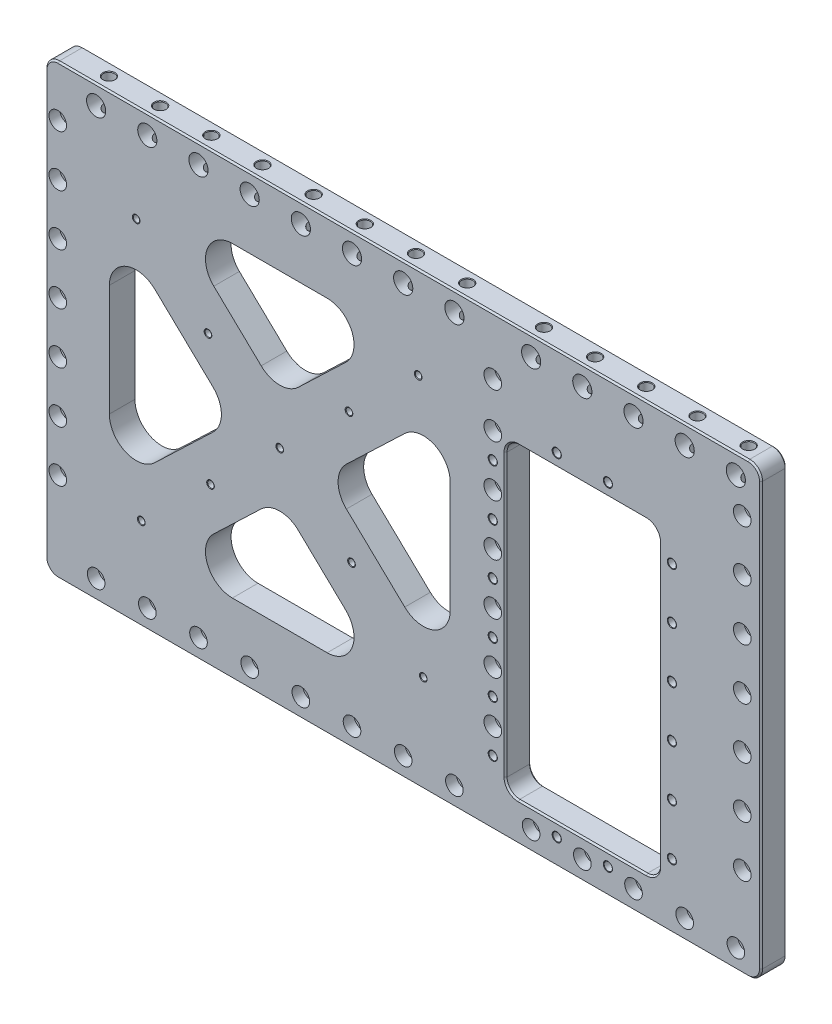
from build123d import *

# Parameters (mm, degrees)
SKETCH1_W                                     = 710.438
SKETCH1_H                                     = 444.5
EXTRUDE1_DEPTH                                = 12.7
CBORE_FOR_3_8_SOCKET_HEAD_CAP_SCREW1_AT_COUNT = 2
CBORE_FOR_3_8_SOCKET_HEAD_CAP_SCREW1_AT_PITCH = 679.45
LPATTERN1_COUNT                               = 4
LPATTERN1_PITCH                               = 50.8
LPATTERN1_COL_COUNT                           = 4
LPATTERN1_COL_PITCH                           = 50.8
CUT_EXTRUDE2_DEPTH                            = 26.4
FILLET2_R                                     = 26.67
F_3_4_0_75_DIAMETER_HOLE1_D                   = 19.05
LPATTERN4_COUNT                               = 4
LPATTERN4_PITCH                               = 50.8
LPATTERN4_COL_COUNT                           = 5
LPATTERN4_COL_PITCH                           = 50.8
LPATTERN5_COUNT                               = 3
LPATTERN5_PITCH                               = 50.8
LPATTERN5_COL_COUNT                           = 4
LPATTERN5_COL_PITCH                           = 50.8
F_1_4_20_TAPPED_HOLE1_AT_2_COUNT              = 2
F_1_4_20_TAPPED_HOLE1_AT_2_PITCH              = 190.037921495
F_1_4_20_TAPPED_HOLE1_AT_3_COUNT              = 2
F_1_4_20_TAPPED_HOLE1_AT_3_PITCH              = 95.018960748
F_1_4_20_TAPPED_HOLE1_AT_4_COUNT              = 2
F_1_4_20_TAPPED_HOLE1_AT_4_PITCH              = 205.096633952
F_1_4_20_TAPPED_HOLE1_AT_5_COUNT              = 2
F_1_4_20_TAPPED_HOLE1_AT_5_PITCH              = 257.044845725
F_1_4_20_TAPPED_HOLE1_AT_6_COUNT              = 2
F_1_4_20_TAPPED_HOLE1_AT_6_PITCH              = 380.07584299
F_1_4_20_TAPPED_HOLE1_AT_7_COUNT              = 2
F_1_4_20_TAPPED_HOLE1_AT_7_PITCH              = 285.056882243
F_1_4_20_TAPPED_HOLE1_AT_8_COUNT              = 2
F_1_4_20_TAPPED_HOLE1_AT_8_PITCH              = 219.593715204
F_1_4_20_TAPPED_HOLE1_AT_9_COUNT              = 2
F_1_4_20_TAPPED_HOLE1_AT_9_PITCH              = 279.974273302
F_3_4_0_75_DIAMETER_HOLE2_D                   = 19.05
LPATTERN6_COUNT                               = 5
LPATTERN6_PITCH                               = 50.8
FILLET3_R                                     = 12.7
CHAMFER1_SIZE                                 = 1.524
CUT_EXTRUDE5_DEPTH                            = 26.4000001
TAPPED_HOLE_FOR_1_4_20_HELICOIL1_AT_2_COUNT   = 2
TAPPED_HOLE_FOR_1_4_20_HELICOIL1_AT_2_PITCH   = 50.8
TAPPED_HOLE_FOR_1_4_20_HELICOIL1_AT_3_COUNT   = 2
TAPPED_HOLE_FOR_1_4_20_HELICOIL1_AT_3_PITCH   = 101.6
TAPPED_HOLE_FOR_1_4_20_HELICOIL1_AT_4_COUNT   = 2
TAPPED_HOLE_FOR_1_4_20_HELICOIL1_AT_4_PITCH   = 152.4
TAPPED_HOLE_FOR_1_4_20_HELICOIL1_AT_5_COUNT   = 2
TAPPED_HOLE_FOR_1_4_20_HELICOIL1_AT_5_PITCH   = 200.804631421
TAPPED_HOLE_FOR_1_4_20_HELICOIL1_AT_6_COUNT   = 2
TAPPED_HOLE_FOR_1_4_20_HELICOIL1_AT_6_PITCH   = 222.159267194
TAPPED_HOLE_FOR_1_4_20_HELICOIL1_AT_7_COUNT   = 2
TAPPED_HOLE_FOR_1_4_20_HELICOIL1_AT_7_PITCH   = 234.176429215
TAPPED_HOLE_FOR_1_4_20_HELICOIL1_AT_8_COUNT   = 2
TAPPED_HOLE_FOR_1_4_20_HELICOIL1_AT_8_PITCH   = 204.781346807
TAPPED_HOLE_FOR_1_4_20_HELICOIL1_AT_9_COUNT   = 2
TAPPED_HOLE_FOR_1_4_20_HELICOIL1_AT_9_PITCH   = 184.914791188
TAPPED_HOLE_FOR_1_4_20_HELICOIL1_AT_10_COUNT  = 2
TAPPED_HOLE_FOR_1_4_20_HELICOIL1_AT_10_PITCH  = 177.8
TAPPED_HOLE_FOR_1_4_20_HELICOIL1_AT_11_COUNT  = 2
TAPPED_HOLE_FOR_1_4_20_HELICOIL1_AT_11_PITCH  = 184.914791188
TAPPED_HOLE_FOR_1_4_20_HELICOIL1_AT_12_COUNT  = 2
TAPPED_HOLE_FOR_1_4_20_HELICOIL1_AT_12_PITCH  = 204.781346807
TAPPED_HOLE_FOR_1_4_20_HELICOIL1_AT_13_COUNT  = 2
TAPPED_HOLE_FOR_1_4_20_HELICOIL1_AT_13_PITCH  = 153.454683865
TAPPED_HOLE_FOR_1_4_20_HELICOIL1_AT_14_COUNT  = 2
TAPPED_HOLE_FOR_1_4_20_HELICOIL1_AT_14_PITCH  = 180.500914125
TAPPED_HOLE_FOR_1_4_20_HELICOIL1_AT_15_COUNT  = 2
TAPPED_HOLE_FOR_1_4_20_HELICOIL1_AT_15_PITCH  = 50.8
TAPPED_HOLE_FOR_1_4_20_HELICOIL1_AT_16_COUNT  = 2
TAPPED_HOLE_FOR_1_4_20_HELICOIL1_AT_16_PITCH  = 101.6
CHAMFER2_SIZE                                 = 1.524
EXTRUDE2_DEPTH                                = 12.7
LPATTERN7_COUNT                               = 6
LPATTERN7_PITCH                               = 50.8
EXTRUDE3_DEPTH                                = 12.7
LPATTERN8_COUNT                               = 2
LPATTERN8_PITCH                               = 50.8


with BuildPart() as part:
    # Sketch1 → Extrude1 (new body, symmetric)
    with BuildSketch(Plane.XY):
        Rectangle(SKETCH1_W, SKETCH1_H)
    extrude(amount=EXTRUDE1_DEPTH, both=True)

    # Sketch2 → CBORE for 3/8 Socket Head Cap Screw1 (revolve, cut)
    with BuildSketch(Plane(origin=(-342.9, 19.05, 12.7), x_dir=(0, -1, 0), z_dir=(1, 0, 0))):
        Polygon((0, 0), (0, 25.4), (5.842, 25.4), (5.15874, 24.613999282), (5.15874, 10.668), (8.7376, 10.668), (8.7376, 0), align=None)
    cbore_for_3_8_socket_head_cap_screw1 = revolve(axis=Axis((-342.9, 19.05, 19.05), (0, 0, -1)), mode=Mode.SUBTRACT)

    # CBORE for 3/8 Socket Head Cap Screw1 at: CBORE for 3/8 Socket Head Cap Screw1 ×2
    with Locations(*[(i * CBORE_FOR_3_8_SOCKET_HEAD_CAP_SCREW1_AT_PITCH, 0, 0) for i in range(1, CBORE_FOR_3_8_SOCKET_HEAD_CAP_SCREW1_AT_COUNT)]):
        add(cbore_for_3_8_socket_head_cap_screw1, mode=Mode.SUBTRACT)

    # LPattern1: CBORE for 3/8 Socket Head Cap Screw1 ×4
    with Locations(*[(0, -i * LPATTERN1_PITCH, 0) for i in range(1, LPATTERN1_COUNT)]):
        add(cbore_for_3_8_socket_head_cap_screw1, mode=Mode.SUBTRACT)

    # LPattern1 copy 1 sketch → LPattern1 copy 1 (revolve, cut)
    with BuildSketch(Plane(origin=(336.55, -31.75, 12.7), x_dir=(0, -1, 0), z_dir=(1, 0, 0))):
        Polygon((0, 0), (0, 25.4), (5.842, 25.4), (5.15874, 24.613999282), (5.15874, 10.668), (8.7376, 10.668), (8.7376, 0), align=None)
    revolve(axis=Axis((336.55, -31.75, 19.05), (0, 0, -1)), mode=Mode.SUBTRACT)

    # LPattern1 copy 2 sketch → LPattern1 copy 2 (revolve, cut)
    with BuildSketch(Plane(origin=(336.55, -82.55, 12.7), x_dir=(0, -1, 0), z_dir=(1, 0, 0))):
        Polygon((0, 0), (0, 25.4), (5.842, 25.4), (5.15874, 24.613999282), (5.15874, 10.668), (8.7376, 10.668), (8.7376, 0), align=None)
    revolve(axis=Axis((336.55, -82.55, 19.05), (0, 0, -1)), mode=Mode.SUBTRACT)

    # LPattern1 copy 3 sketch → LPattern1 copy 3 (revolve, cut)
    with BuildSketch(Plane(origin=(336.55, -133.35, 12.7), x_dir=(0, -1, 0), z_dir=(1, 0, 0))):
        Polygon((0, 0), (0, 25.4), (5.842, 25.4), (5.15874, 24.613999282), (5.15874, 10.668), (8.7376, 10.668), (8.7376, 0), align=None)
    revolve(axis=Axis((336.55, -133.35, 19.05), (0, 0, -1)), mode=Mode.SUBTRACT)

    # LPattern1 col: CBORE for 3/8 Socket Head Cap Screw1 ×4
    with Locations(*[(0, i * LPATTERN1_COL_PITCH, 0) for i in range(1, LPATTERN1_COL_COUNT)]):
        add(cbore_for_3_8_socket_head_cap_screw1, mode=Mode.SUBTRACT)

    # LPattern1 col copy 1 sketch → LPattern1 col copy 1 (revolve, cut)
    with BuildSketch(Plane(origin=(336.55, 69.85, 12.7), x_dir=(0, -1, 0), z_dir=(1, 0, 0))):
        Polygon((0, 0), (0, 25.4), (5.842, 25.4), (5.15874, 24.613999282), (5.15874, 10.668), (8.7376, 10.668), (8.7376, 0), align=None)
    revolve(axis=Axis((336.55, 69.85, 19.05), (0, 0, -1)), mode=Mode.SUBTRACT)

    # LPattern1 col copy 2 sketch → LPattern1 col copy 2 (revolve, cut)
    with BuildSketch(Plane(origin=(336.55, 120.65, 12.7), x_dir=(0, -1, 0), z_dir=(1, 0, 0))):
        Polygon((0, 0), (0, 25.4), (5.842, 25.4), (5.15874, 24.613999282), (5.15874, 10.668), (8.7376, 10.668), (8.7376, 0), align=None)
    revolve(axis=Axis((336.55, 120.65, 19.05), (0, 0, -1)), mode=Mode.SUBTRACT)

    # LPattern1 col copy 3 sketch → LPattern1 col copy 3 (revolve, cut)
    with BuildSketch(Plane(origin=(336.55, 171.45, 12.7), x_dir=(0, -1, 0), z_dir=(1, 0, 0))):
        Polygon((0, 0), (0, 25.4), (5.842, 25.4), (5.15874, 24.613999282), (5.15874, 10.668), (8.7376, 10.668), (8.7376, 0), align=None)
    revolve(axis=Axis((336.55, 171.45, 19.05), (0, 0, -1)), mode=Mode.SUBTRACT)

    # Sketch9 → Cut-Extrude2 (cut, through all)
    with BuildSketch(Plane.XY.offset(12.7)):
        Polygon((-8.969055228, 152.4), (-122.5485484, 43.907313525), (-236.128041572, 152.4), align=None)
        Polygon((-291.719, 117.686617331), (-168.514507754, 0), (-291.719, -117.686617331), align=None)
        Polygon((-122.5485484, -43.907313525), (-236.128041572, -152.4), (-8.969055228, -152.4), align=None)
        Polygon((46.6219032, 117.686617331), (46.6219032, -117.686617331), (-76.582589046, 0), align=None)
    extrude(amount=-CUT_EXTRUDE2_DEPTH, mode=Mode.SUBTRACT)

    # Fillet2
    fillet2_edges = [part.edges().sort_by_distance(p)[0] for p in [
        (-236.128041572, 152.4, 0),
        (-8.969055228, 152.4, 0),
        (-122.5485484, 43.907313525, 0),
        (-291.719, -117.686617331, 0),
        (-291.719, 117.686617331, 0),
        (-168.514507754, 0, 0),
        (-122.5485484, -43.907313525, 0),
        (-8.969055228, -152.4, 0),
        (-236.128041572, -152.4, 0),
        (-76.582589046, 0, 0),
        (46.6219032, 117.686617331, 0),
        (46.6219032, -117.686617331, 0),
    ]]
    fillet(fillet2_edges, radius=FILLET2_R)

    # Sketch4 → CBORE for 3/8 Socket Head Cap Screw2 (revolve, cut)
    with BuildSketch(Plane(origin=(-152.4, -203.2, 12.7), x_dir=(0, -1, 0), z_dir=(1, 0, 0))):
        Polygon((0, 0), (0, 25.4), (5.842, 25.4), (5.15874, 24.613999282), (5.15874, 10.668), (8.7376, 10.668), (8.7376, 0), align=None)
    cbore_for_3_8_socket_head_cap_screw2 = revolve(axis=Axis((-152.4, -203.2, 19.05), (0, 0, -1)), mode=Mode.SUBTRACT)

    # Sketch14 → 7/16 (0.4375) Diameter Hole1 (revolve, cut)
    with BuildSketch(Plane(origin=(-152.4, 222.25, 0), x_dir=(0, 0, 1), z_dir=(1, 0, 0))):
        Polygon((0, 0), (0, 38.263531814), (5.55625, 34.925), (5.55625, 0.620911348), (6.096, 0), align=None)
    f_7_16_0_4375_diameter_hole1 = revolve(axis=Axis((-152.4, 228.6, 0), (0, -1, 0)), mode=Mode.SUBTRACT)

    # 3/4 (0.75) Diameter Hole1 (through all)
    with Locations(Plane.XY.offset(12.7)):
        with Locations((-152.4, 203.2)):
            f_3_4_0_75_diameter_hole1 = Hole(F_3_4_0_75_DIAMETER_HOLE1_D / 2)

    # LPattern4: CBORE for 3/8 Socket Head Cap Screw2, 7/16 (0.4375) Diameter Hole1, 3/4 (0.75) Diameter Hole1 ×4
    with Locations(*[(-i * LPATTERN4_PITCH, 0, 0) for i in range(1, LPATTERN4_COUNT)]):
        add(cbore_for_3_8_socket_head_cap_screw2, mode=Mode.SUBTRACT)
        add(f_7_16_0_4375_diameter_hole1, mode=Mode.SUBTRACT)
        add(f_3_4_0_75_diameter_hole1, mode=Mode.SUBTRACT)

    # LPattern4 col: CBORE for 3/8 Socket Head Cap Screw2, 7/16 (0.4375) Diameter Hole1, 3/4 (0.75) Diameter Hole1 ×5
    with Locations(*[(i * LPATTERN4_COL_PITCH, 0, 0) for i in range(1, LPATTERN4_COL_COUNT)]):
        add(cbore_for_3_8_socket_head_cap_screw2, mode=Mode.SUBTRACT)
        add(f_7_16_0_4375_diameter_hole1, mode=Mode.SUBTRACT)
        add(f_3_4_0_75_diameter_hole1, mode=Mode.SUBTRACT)

    # Sketch16 → CBORE for 3/8 Socket Head Cap Screw3 (revolve, cut)
    with BuildSketch(Plane(origin=(88.9, 19.05, 12.7), x_dir=(0, -1, 0), z_dir=(1, 0, 0))):
        Polygon((0, 0), (0, 25.4), (5.842, 25.4), (5.15874, 24.613999282), (5.15874, 10.668), (8.7376, 10.668), (8.7376, 0), align=None)
    cbore_for_3_8_socket_head_cap_screw3 = revolve(axis=Axis((88.9, 19.05, 19.05), (0, 0, -1)), mode=Mode.SUBTRACT)

    # LPattern5: CBORE for 3/8 Socket Head Cap Screw3 ×3
    with Locations(*[(0, i * LPATTERN5_PITCH, 0) for i in range(1, LPATTERN5_COUNT)]):
        add(cbore_for_3_8_socket_head_cap_screw3, mode=Mode.SUBTRACT)

    # LPattern5 col: CBORE for 3/8 Socket Head Cap Screw3 ×4
    with Locations(*[(0, -i * LPATTERN5_COL_PITCH, 0) for i in range(1, LPATTERN5_COL_COUNT)]):
        add(cbore_for_3_8_socket_head_cap_screw3, mode=Mode.SUBTRACT)

    # Sketch27 → CBORE for 3/8 Socket Head Cap Screw4 (revolve, cut)
    with BuildSketch(Plane(origin=(88.9, 165.1, 12.7), x_dir=(0, -1, 0), z_dir=(1, 0, 0))):
        Polygon((0, 0), (0, 25.4), (5.842, 25.4), (5.15874, 24.613999282), (5.15874, 10.668), (8.7376, 10.668), (8.7376, 0), align=None)
    revolve(axis=Axis((88.9, 165.1, 19.05), (0, 0, -1)), mode=Mode.SUBTRACT)

    # Sketch24 → 1/4-20 Tapped Hole1 (revolve, cut)
    with BuildSketch(Plane(origin=(19.9519032, -125.73, 12.7), x_dir=(0, -1, 0), z_dir=(1, 0, 0))):
        Polygon((0, 0), (0, 25.4), (2.5527, 25.4), (2.5527, 12.7), (3.175, 12.7), (3.175, 0.366617421), (3.81, 0), align=None)
    f_1_4_20_tapped_hole1 = revolve(axis=Axis((19.9519032, -125.73, 19.05), (0, 0, -1)), mode=Mode.SUBTRACT)

    # 1/4-20 Tapped Hole1 at 2: 1/4-20 Tapped Hole1 ×2
    with Locations(*[Vector(-0.749852716, 0.661604795, 0) * (i * F_1_4_20_TAPPED_HOLE1_AT_2_PITCH) for i in range(1, F_1_4_20_TAPPED_HOLE1_AT_2_COUNT)]):
        add(f_1_4_20_tapped_hole1, mode=Mode.SUBTRACT)

    # 1/4-20 Tapped Hole1 at 3: 1/4-20 Tapped Hole1 ×2
    with Locations(*[Vector(-0.749852716, 0.661604795, 0) * (i * F_1_4_20_TAPPED_HOLE1_AT_3_PITCH) for i in range(1, F_1_4_20_TAPPED_HOLE1_AT_3_COUNT)]):
        add(f_1_4_20_tapped_hole1, mode=Mode.SUBTRACT)

    # 1/4-20 Tapped Hole1 at 4: 1/4-20 Tapped Hole1 ×2
    with Locations(*[Vector(-0.359785992, 0.933034855, 0) * (i * F_1_4_20_TAPPED_HOLE1_AT_4_PITCH) for i in range(1, F_1_4_20_TAPPED_HOLE1_AT_4_COUNT)]):
        add(f_1_4_20_tapped_hole1, mode=Mode.SUBTRACT)

    # 1/4-20 Tapped Hole1 at 5: 1/4-20 Tapped Hole1 ×2
    with Locations(*[Vector(-0.019768302, 0.999804588, 0) * (i * F_1_4_20_TAPPED_HOLE1_AT_5_PITCH) for i in range(1, F_1_4_20_TAPPED_HOLE1_AT_5_COUNT)]):
        add(f_1_4_20_tapped_hole1, mode=Mode.SUBTRACT)

    # 1/4-20 Tapped Hole1 at 6: 1/4-20 Tapped Hole1 ×2
    with Locations(*[Vector(-0.749852716, 0.661604795, 0) * (i * F_1_4_20_TAPPED_HOLE1_AT_6_PITCH) for i in range(1, F_1_4_20_TAPPED_HOLE1_AT_6_COUNT)]):
        add(f_1_4_20_tapped_hole1, mode=Mode.SUBTRACT)

    # 1/4-20 Tapped Hole1 at 7: 1/4-20 Tapped Hole1 ×2
    with Locations(*[Vector(-0.749852716, 0.661604795, 0) * (i * F_1_4_20_TAPPED_HOLE1_AT_7_PITCH) for i in range(1, F_1_4_20_TAPPED_HOLE1_AT_7_COUNT)]):
        add(f_1_4_20_tapped_hole1, mode=Mode.SUBTRACT)

    # 1/4-20 Tapped Hole1 at 8: 1/4-20 Tapped Hole1 ×2
    with Locations(*[Vector(-0.961821731, 0.273676739, 0) * (i * F_1_4_20_TAPPED_HOLE1_AT_8_PITCH) for i in range(1, F_1_4_20_TAPPED_HOLE1_AT_8_COUNT)]):
        add(f_1_4_20_tapped_hole1, mode=Mode.SUBTRACT)

    # 1/4-20 Tapped Hole1 at 9: 1/4-20 Tapped Hole1 ×2
    with Locations(*[Vector(-0.999804588, -0.019768302, 0) * (i * F_1_4_20_TAPPED_HOLE1_AT_9_PITCH) for i in range(1, F_1_4_20_TAPPED_HOLE1_AT_9_COUNT)]):
        add(f_1_4_20_tapped_hole1, mode=Mode.SUBTRACT)

    # Sketch30 → CBORE for 3/8 Socket Head Cap Screw5 (revolve, cut)
    with BuildSketch(Plane(origin=(127, -203.2, 12.7), x_dir=(0, -1, 0), z_dir=(1, 0, 0))):
        Polygon((0, 0), (0, 25.4), (5.842, 25.4), (5.15874, 24.613999282), (5.15874, 10.668), (8.7376, 10.668), (8.7376, 0), align=None)
    cbore_for_3_8_socket_head_cap_screw5 = revolve(axis=Axis((127, -203.2, 19.05), (0, 0, -1)), mode=Mode.SUBTRACT)

    # Sketch32 → 7/16 (0.4375) Diameter Hole2 (revolve, cut)
    with BuildSketch(Plane(origin=(127, 222.25, 0), x_dir=(0, 0, 1), z_dir=(1, 0, 0))):
        Polygon((0, 0), (0, 38.263531814), (5.55625, 34.925), (5.55625, 0.620911348), (6.096, 0), align=None)
    f_7_16_0_4375_diameter_hole2 = revolve(axis=Axis((127, 228.6, 0), (0, -1, 0)), mode=Mode.SUBTRACT)

    # 3/4 (0.75) Diameter Hole2 (through all)
    with Locations(Plane.XY.offset(12.7)):
        with Locations((127, 203.2)):
            f_3_4_0_75_diameter_hole2 = Hole(F_3_4_0_75_DIAMETER_HOLE2_D / 2)

    # LPattern6: CBORE for 3/8 Socket Head Cap Screw5, 7/16 (0.4375) Diameter Hole2, 3/4 (0.75) Diameter Hole2 ×5
    with Locations(*[(i * LPATTERN6_PITCH, 0, 0) for i in range(1, LPATTERN6_COUNT)]):
        add(cbore_for_3_8_socket_head_cap_screw5, mode=Mode.SUBTRACT)
        add(f_7_16_0_4375_diameter_hole2, mode=Mode.SUBTRACT)
        add(f_3_4_0_75_diameter_hole2, mode=Mode.SUBTRACT)

    # Fillet3
    fillet3_edges = [part.edges().sort_by_distance(p)[0] for p in [
        (-355.219, 222.25, 0),
        (355.219, 222.25, 0),
        (355.219, -222.25, 0),
        (-355.219, -222.25, 0),
    ]]
    fillet(fillet3_edges, radius=FILLET3_R)

    # Chamfer1
    chamfer1_edges = [part.edges().sort_by_distance(p)[0] for p in [
        (355.219, 0, -12.7),
        (355.219, 0, 12.7),
        (-355.219, 0, -12.7),
        (0, 222.25, -12.7),
        (0, -222.25, -12.7),
        (-351.499256121, 218.530256121, -12.7),
        (351.499256121, 218.530256121, -12.7),
        (-351.499256121, -218.530256121, -12.7),
        (351.499256121, -218.530256121, -12.7),
        (0, -222.25, 12.7),
        (-355.219, 0, 12.7),
        (0, 222.25, 12.7),
        (-351.499256121, 218.530256121, 12.7),
        (351.499256121, 218.530256121, 12.7),
        (-351.499256121, -218.530256121, 12.7),
        (351.499256121, -218.530256121, 12.7),
    ]]
    chamfer(chamfer1_edges, length=CHAMFER1_SIZE)

    # Sketch35 → Cut-Extrude5 (cut, through all)
    with BuildSketch(Plane.XY.offset(12.7)):
        with BuildLine():
            Line((114.3, 120.65), (241.3, 120.65))
            ThreePointArc((241.3, 120.65), (250.280256121, 116.930256121), (254, 107.95))
            Line((254, 107.95), (254, -171.45))
            ThreePointArc((254, -171.45), (250.280256121, -180.430256121), (241.3, -184.15))
            Line((241.3, -184.15), (114.3, -184.15))
            ThreePointArc((114.3, -184.15), (105.319743879, -180.430256121), (101.6, -171.45))
            Line((101.6, -171.45), (101.6, 107.95))
            ThreePointArc((101.6, 107.95), (105.319743879, 116.930256121), (114.3, 120.65))
        make_face()
    extrude(amount=-CUT_EXTRUDE5_DEPTH, mode=Mode.SUBTRACT)

    # Sketch36 → Tapped Hole for 1/4-20 Helicoil1 (revolve, cut)
    with BuildSketch(Plane(origin=(88.9, -6.35, 12.7), x_dir=(0, -1, 0), z_dir=(1, 0, 0))):
        Polygon((0, 0), (0, 25.4), (3.81, 25.4), (3.3782, 24.903270922), (3.3782, 15.7226), (4.04749, 15.7226), (4.04749, 0.30282599), (4.572, 0), align=None)
    tapped_hole_for_1_4_20_helicoil1 = revolve(axis=Axis((88.9, -6.35, 19.05), (0, 0, -1)), mode=Mode.SUBTRACT)

    # Tapped Hole for 1/4-20 Helicoil1 at 2: Tapped Hole for 1/4-20 Helicoil1 ×2
    with Locations(*[(0, -i * TAPPED_HOLE_FOR_1_4_20_HELICOIL1_AT_2_PITCH, 0) for i in range(1, TAPPED_HOLE_FOR_1_4_20_HELICOIL1_AT_2_COUNT)]):
        add(tapped_hole_for_1_4_20_helicoil1, mode=Mode.SUBTRACT)

    # Tapped Hole for 1/4-20 Helicoil1 at 3: Tapped Hole for 1/4-20 Helicoil1 ×2
    with Locations(*[(0, -i * TAPPED_HOLE_FOR_1_4_20_HELICOIL1_AT_3_PITCH, 0) for i in range(1, TAPPED_HOLE_FOR_1_4_20_HELICOIL1_AT_3_COUNT)]):
        add(tapped_hole_for_1_4_20_helicoil1, mode=Mode.SUBTRACT)

    # Tapped Hole for 1/4-20 Helicoil1 at 4: Tapped Hole for 1/4-20 Helicoil1 ×2
    with Locations(*[(0, -i * TAPPED_HOLE_FOR_1_4_20_HELICOIL1_AT_4_PITCH, 0) for i in range(1, TAPPED_HOLE_FOR_1_4_20_HELICOIL1_AT_4_COUNT)]):
        add(tapped_hole_for_1_4_20_helicoil1, mode=Mode.SUBTRACT)

    # Tapped Hole for 1/4-20 Helicoil1 at 5: Tapped Hole for 1/4-20 Helicoil1 ×2
    with Locations(*[Vector(0.316227766, -0.948683298, 0) * (i * TAPPED_HOLE_FOR_1_4_20_HELICOIL1_AT_5_PITCH) for i in range(1, TAPPED_HOLE_FOR_1_4_20_HELICOIL1_AT_5_COUNT)]):
        add(tapped_hole_for_1_4_20_helicoil1, mode=Mode.SUBTRACT)

    # Tapped Hole for 1/4-20 Helicoil1 at 6: Tapped Hole for 1/4-20 Helicoil1 ×2
    with Locations(*[Vector(0.514495755, -0.857492926, 0) * (i * TAPPED_HOLE_FOR_1_4_20_HELICOIL1_AT_6_PITCH) for i in range(1, TAPPED_HOLE_FOR_1_4_20_HELICOIL1_AT_6_COUNT)]):
        add(tapped_hole_for_1_4_20_helicoil1, mode=Mode.SUBTRACT)

    # Tapped Hole for 1/4-20 Helicoil1 at 7: Tapped Hole for 1/4-20 Helicoil1 ×2
    with Locations(*[Vector(0.759256602, -0.650791373, 0) * (i * TAPPED_HOLE_FOR_1_4_20_HELICOIL1_AT_7_PITCH) for i in range(1, TAPPED_HOLE_FOR_1_4_20_HELICOIL1_AT_7_COUNT)]):
        add(tapped_hole_for_1_4_20_helicoil1, mode=Mode.SUBTRACT)

    # Tapped Hole for 1/4-20 Helicoil1 at 8: Tapped Hole for 1/4-20 Helicoil1 ×2
    with Locations(*[Vector(0.868243142, -0.496138938, 0) * (i * TAPPED_HOLE_FOR_1_4_20_HELICOIL1_AT_8_PITCH) for i in range(1, TAPPED_HOLE_FOR_1_4_20_HELICOIL1_AT_8_COUNT)]):
        add(tapped_hole_for_1_4_20_helicoil1, mode=Mode.SUBTRACT)

    # Tapped Hole for 1/4-20 Helicoil1 at 9: Tapped Hole for 1/4-20 Helicoil1 ×2
    with Locations(*[Vector(0.961523948, -0.274721128, 0) * (i * TAPPED_HOLE_FOR_1_4_20_HELICOIL1_AT_9_PITCH) for i in range(1, TAPPED_HOLE_FOR_1_4_20_HELICOIL1_AT_9_COUNT)]):
        add(tapped_hole_for_1_4_20_helicoil1, mode=Mode.SUBTRACT)

    # Tapped Hole for 1/4-20 Helicoil1 at 10: Tapped Hole for 1/4-20 Helicoil1 ×2
    with Locations(*[(i * TAPPED_HOLE_FOR_1_4_20_HELICOIL1_AT_10_PITCH, 0, 0) for i in range(1, TAPPED_HOLE_FOR_1_4_20_HELICOIL1_AT_10_COUNT)]):
        add(tapped_hole_for_1_4_20_helicoil1, mode=Mode.SUBTRACT)

    # Tapped Hole for 1/4-20 Helicoil1 at 11: Tapped Hole for 1/4-20 Helicoil1 ×2
    with Locations(*[Vector(0.961523948, 0.274721128, 0) * (i * TAPPED_HOLE_FOR_1_4_20_HELICOIL1_AT_11_PITCH) for i in range(1, TAPPED_HOLE_FOR_1_4_20_HELICOIL1_AT_11_COUNT)]):
        add(tapped_hole_for_1_4_20_helicoil1, mode=Mode.SUBTRACT)

    # Tapped Hole for 1/4-20 Helicoil1 at 12: Tapped Hole for 1/4-20 Helicoil1 ×2
    with Locations(*[Vector(0.868243142, 0.496138938, 0) * (i * TAPPED_HOLE_FOR_1_4_20_HELICOIL1_AT_12_PITCH) for i in range(1, TAPPED_HOLE_FOR_1_4_20_HELICOIL1_AT_12_COUNT)]):
        add(tapped_hole_for_1_4_20_helicoil1, mode=Mode.SUBTRACT)

    # Tapped Hole for 1/4-20 Helicoil1 at 13: Tapped Hole for 1/4-20 Helicoil1 ×2
    with Locations(*[Vector(0.413802944, 0.910366477, 0) * (i * TAPPED_HOLE_FOR_1_4_20_HELICOIL1_AT_13_PITCH) for i in range(1, TAPPED_HOLE_FOR_1_4_20_HELICOIL1_AT_13_COUNT)]):
        add(tapped_hole_for_1_4_20_helicoil1, mode=Mode.SUBTRACT)

    # Tapped Hole for 1/4-20 Helicoil1 at 14: Tapped Hole for 1/4-20 Helicoil1 ×2
    with Locations(*[Vector(0.63323779, 0.773957299, 0) * (i * TAPPED_HOLE_FOR_1_4_20_HELICOIL1_AT_14_PITCH) for i in range(1, TAPPED_HOLE_FOR_1_4_20_HELICOIL1_AT_14_COUNT)]):
        add(tapped_hole_for_1_4_20_helicoil1, mode=Mode.SUBTRACT)

    # Tapped Hole for 1/4-20 Helicoil1 at 15: Tapped Hole for 1/4-20 Helicoil1 ×2
    with Locations(*[(0, i * TAPPED_HOLE_FOR_1_4_20_HELICOIL1_AT_15_PITCH, 0) for i in range(1, TAPPED_HOLE_FOR_1_4_20_HELICOIL1_AT_15_COUNT)]):
        add(tapped_hole_for_1_4_20_helicoil1, mode=Mode.SUBTRACT)

    # Tapped Hole for 1/4-20 Helicoil1 at 16: Tapped Hole for 1/4-20 Helicoil1 ×2
    with Locations(*[(0, i * TAPPED_HOLE_FOR_1_4_20_HELICOIL1_AT_16_PITCH, 0) for i in range(1, TAPPED_HOLE_FOR_1_4_20_HELICOIL1_AT_16_COUNT)]):
        add(tapped_hole_for_1_4_20_helicoil1, mode=Mode.SUBTRACT)

    # Chamfer2
    chamfer2_edges = [part.edges().sort_by_distance(p)[0] for p in [
        (105.319743879, 116.930256121, -12.7),
        (177.8, 120.65, -12.7),
        (250.280256121, 116.930256121, -12.7),
        (254, -31.75, -12.7),
        (250.280256121, -180.430256121, -12.7),
        (177.8, -184.15, -12.7),
        (105.319743879, -180.430256121, -12.7),
        (101.6, -31.75, -12.7),
        (105.319743879, 116.930256121, 12.7),
        (101.6, -31.75, 12.7),
        (105.319743879, -180.430256121, 12.7),
        (177.8, -184.15, 12.7),
        (250.280256121, -180.430256121, 12.7),
        (254, -31.75, 12.7),
        (250.280256121, 116.930256121, 12.7),
        (177.8, 120.65, 12.7),
    ]]
    chamfer(chamfer2_edges, length=CHAMFER2_SIZE)

    # Sketch38 → Extrude2 (cut)
    with BuildSketch(Plane(origin=(101.6, 0, 0), x_dir=(0, 0, -1), z_dir=(1, 0, 0))):
        with BuildLine():
            Line((12.7, 97.738681579), (12.7, 92.761318421))
            ThreePointArc((12.7, 92.761318421), (12.192, 95.25), (12.7, 97.738681579))
        make_face()
    extrude2 = extrude(amount=-EXTRUDE2_DEPTH, mode=Mode.SUBTRACT)

    # LPattern7: Extrude2 ×6
    with Locations(*[(0, -i * LPATTERN7_PITCH, 0) for i in range(1, LPATTERN7_COUNT)]):
        add(extrude2, mode=Mode.SUBTRACT)

    # Sketch39 → Extrude3 (cut)
    with BuildSketch(Plane(origin=(0, -184.15, 0), x_dir=(1, 0, 0), z_dir=(0, 1, 0))):
        with BuildLine():
            Line((149.911318421, 12.7), (154.888681579, 12.7))
            ThreePointArc((154.888681579, 12.7), (152.4, 12.192), (149.911318421, 12.7))
        make_face()
    extrude3 = extrude(amount=-EXTRUDE3_DEPTH, mode=Mode.SUBTRACT)

    # LPattern8: Extrude3 ×2
    with Locations(*[(i * LPATTERN8_PITCH, 0, 0) for i in range(1, LPATTERN8_COUNT)]):
        add(extrude3, mode=Mode.SUBTRACT)


solid = part.part
